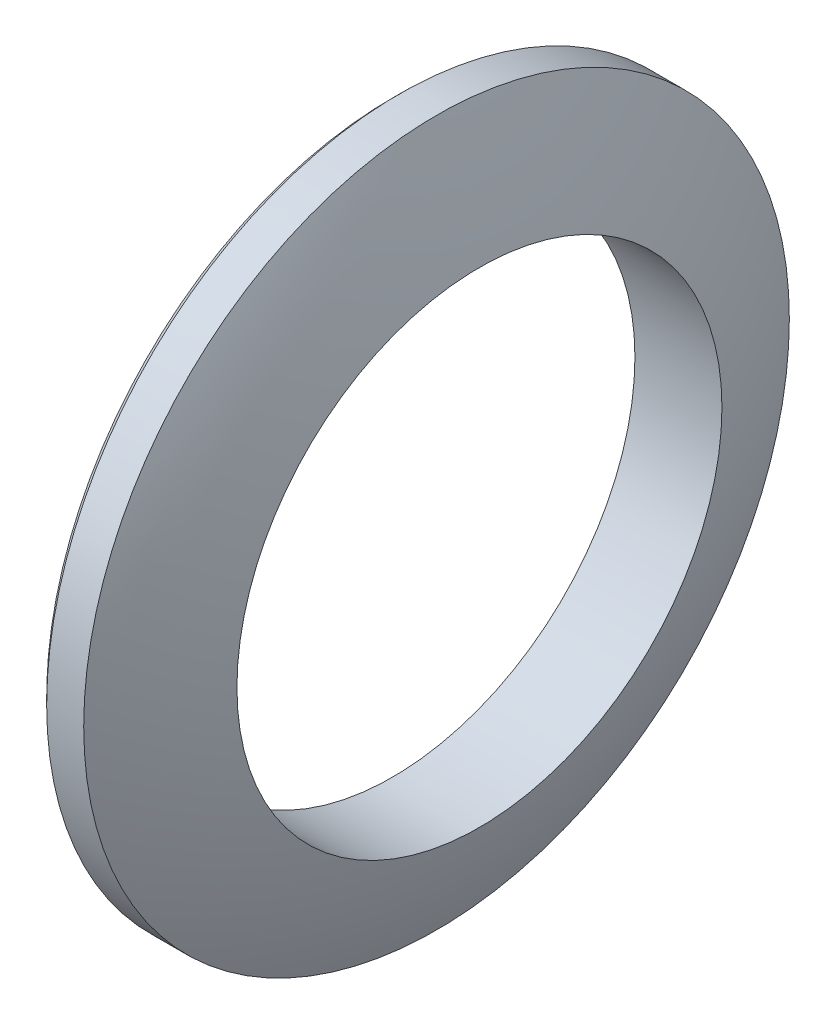
from build123d import *

# Parameters (mm, degrees)
CHAMFER1_SIZE = 0.762


with BuildPart() as part:
    # Sketch1 → Revolve1 (revolve)
    with BuildSketch(Plane.XY, mode=Mode.PRIVATE) as revolve1_sk:
        with BuildLine():
            Line((0, 38.1), (4.7625, 38.1))
            ThreePointArc((4.7625, 38.1), (7.293679798, 32.227085313), (9.396106828, 26.1874))
            Line((9.396106828, 26.1874), (0, 26.1874))
            Line((0, 26.1874), (0, 38.1))
        make_face()
    revolve(revolve1_sk.sketch.rotate(Axis((0, 0, 0), (1, 0, 0)), 90), axis=Axis((0, 0, 0), (1, 0, 0)))  # turned: the seam where the file's is

    # Chamfer1
    chamfer1_edges = [part.edges().sort_by_distance(p)[0] for p in [
        (0, 0, -38.1),
    ]]
    chamfer(chamfer1_edges, length=CHAMFER1_SIZE)


solid = part.part
